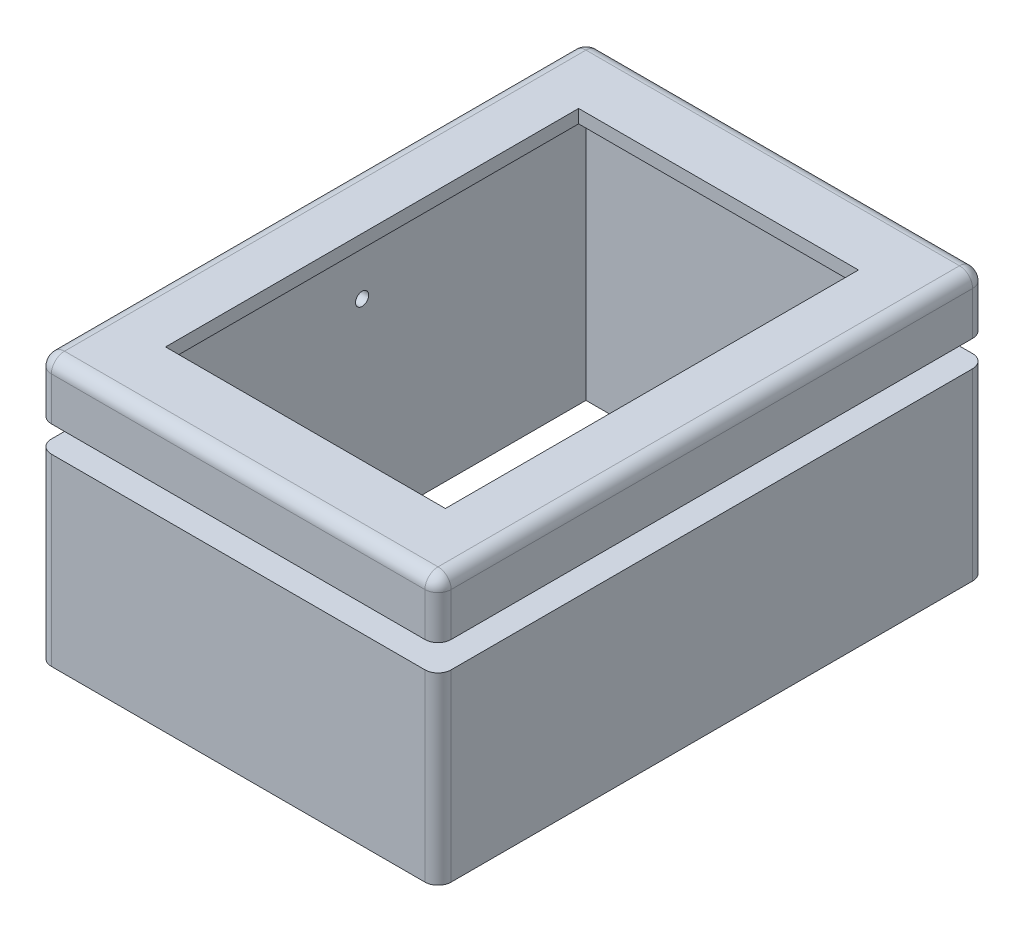
from build123d import *

# Parameters (mm, degrees)
SKETCH1_W           = 15.24
SKETCH1_H           = 20.8788
SKETCH1_W_2         = 10.668
SKETCH1_H_2         = 15.748
BOSS_EXTRUDE1_DEPTH = 10.16
SKETCH2_R           = 0.25
CUT_EXTRUDE1_DEPTH  = 16.24
SKETCH3_W           = 11.43
SKETCH3_H           = 17.0688
CUT_EXTRUDE2_DEPTH  = 9.652
SKETCH5_W           = 15.24
SKETCH5_H           = 20.8788
SKETCH5_W_2         = 12.24
SKETCH5_H_2         = 17.8788
CUT_EXTRUDE4_DEPTH  = 1
FILLET1_R           = 0.5


with BuildPart() as part:
    # Sketch1 → Boss-Extrude1 (new body)
    with BuildSketch(Plane(origin=(0, 0, 0), x_dir=(1, 0, 0), z_dir=(0, 1, 0))):
        with Locations((7.62, 10.4394)):
            Rectangle(SKETCH1_W, SKETCH1_H)
        with Locations((7.62, 10.4394)):
            Rectangle(SKETCH1_W_2, SKETCH1_H_2, mode=Mode.SUBTRACT)
    extrude(amount=BOSS_EXTRUDE1_DEPTH)

    # Sketch2 → Cut-Extrude1 (cut, through all)
    with BuildSketch(Plane(origin=(15.24, 0, 0), x_dir=(0, 0, -1), z_dir=(1, 0, 0))):
        with Locations((10.4394, 7.62)):
            Circle(SKETCH2_R)
    extrude(amount=-CUT_EXTRUDE1_DEPTH, mode=Mode.SUBTRACT)

    # Sketch3 → Cut-Extrude2 (cut)
    with BuildSketch(Plane.XZ):
        with Locations((7.62, -10.4394)):
            Rectangle(SKETCH3_W, SKETCH3_H)
    extrude(amount=-CUT_EXTRUDE2_DEPTH, mode=Mode.SUBTRACT)

    # Sketch5 → Cut-Extrude4 (cut)
    with BuildSketch(Plane(origin=(0, 8.01, 0), x_dir=(1, 0, 0), z_dir=(0, 1, 0))):
        with Locations((7.62, 10.4394)):
            Rectangle(SKETCH5_W, SKETCH5_H)
        with Locations((7.62, 10.4394)):
            Rectangle(SKETCH5_W_2, SKETCH5_H_2, mode=Mode.SUBTRACT)
    extrude(amount=-CUT_EXTRUDE4_DEPTH, mode=Mode.SUBTRACT)

    # Fillet1
    fillet1_edges = [part.edges().sort_by_distance(p)[0] for p in [
        (15.24, 10.16, -10.4394),
        (7.62, 10.16, -20.8788),
        (0, 10.16, -10.4394),
        (0, 3.505, -20.8788),
        (15.24, 3.505, -20.8788),
        (15.24, 3.505, 0),
        (0, 3.505, 0),
        (7.62, 10.16, 0),
        (0, 9.085, -20.8788),
        (15.24, 9.085, -20.8788),
        (15.24, 9.085, 0),
        (0, 9.085, 0),
    ]]
    fillet(fillet1_edges, radius=FILLET1_R)


solid = part.part
